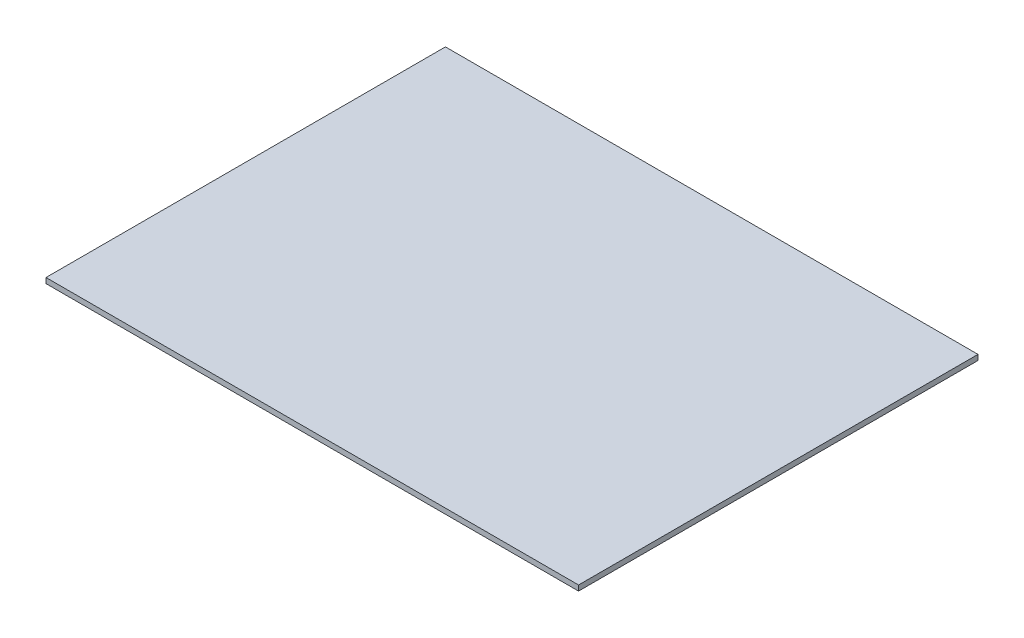
from build123d import *

# Parameters (mm, degrees)
SKETCH_1_W      = 400
SKETCH_1_H      = 300
EXTRUDE_1_DEPTH = 4


with BuildPart() as part:
    # Эскиз1 → Бобышка-Вытянуть1 (new body)
    with BuildSketch(Plane(origin=(0, 0, 0), x_dir=(1, 0, 0), z_dir=(0, 1, 0))):
        Rectangle(SKETCH_1_W, SKETCH_1_H)
    extrude(amount=EXTRUDE_1_DEPTH)


solid = part.part
